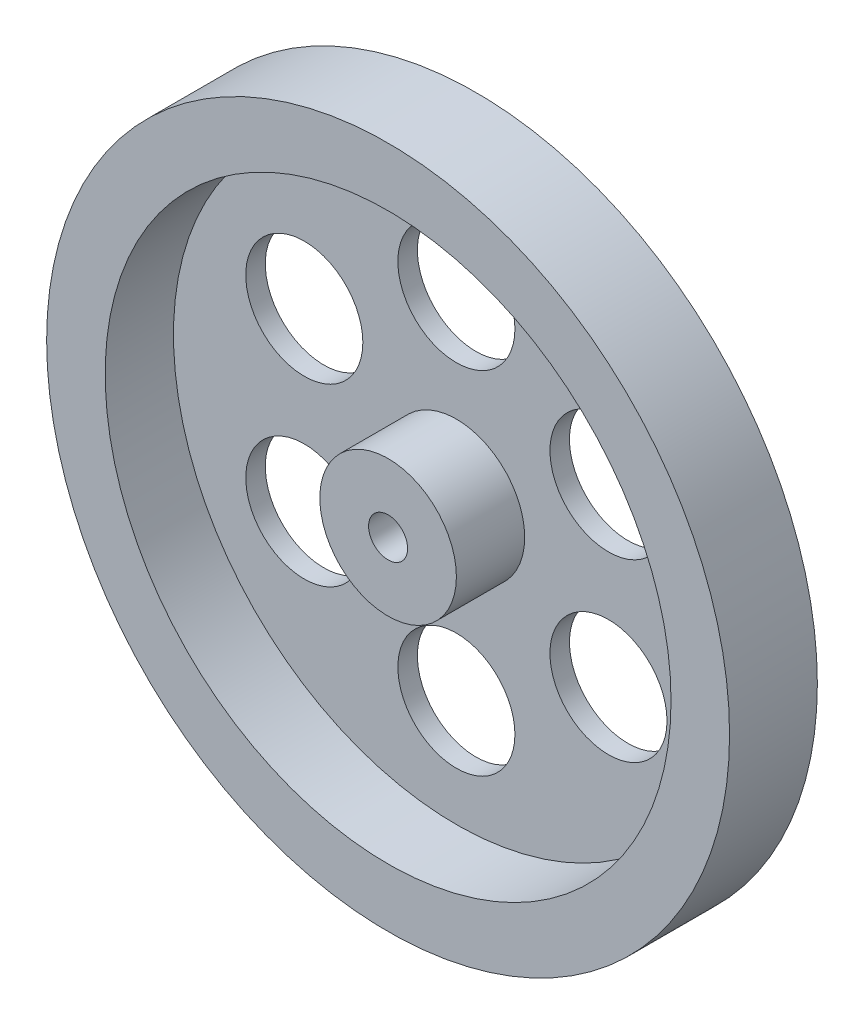
from build123d import *

# Parameters (mm, degrees)
SKETCH1_R               = 35
BOSS_EXTRUDE1_DEPTH     = 9
SKETCH2_R               = 2
CUT_EXTRUDE1_DEPTH      = 1
CUT_EXTRUDE1_DEPTH_BACK = 10
SKETCH3_R               = 29
SKETCH3_R_2             = 7
CUT_EXTRUDE2_DEPTH      = 7
SKETCH4_R               = 6
CUT_EXTRUDE3_DEPTH      = 3


with BuildPart() as part:
    # Sketch1 → Boss-Extrude1 (new body)
    with BuildSketch(Plane.XY):
        Circle(SKETCH1_R)
    extrude(amount=BOSS_EXTRUDE1_DEPTH)

    # Sketch2 → Cut-Extrude1 (cut, two sides)
    with BuildSketch(Plane.XY.offset(9)) as cut_extrude1_sk:
        Circle(SKETCH2_R)
    extrude(amount=CUT_EXTRUDE1_DEPTH, mode=Mode.SUBTRACT)
    extrude(cut_extrude1_sk.sketch, amount=-CUT_EXTRUDE1_DEPTH_BACK, mode=Mode.SUBTRACT)

    # Sketch3 → Cut-Extrude2 (cut)
    with BuildSketch(Plane.XY.offset(9)):
        Circle(SKETCH3_R)
        Circle(SKETCH3_R_2, mode=Mode.SUBTRACT)
    extrude(amount=-CUT_EXTRUDE2_DEPTH, mode=Mode.SUBTRACT)

    # Sketch4 → Cut-Extrude3 (cut, through all)
    with BuildSketch(Plane.XY.offset(2)):
        with Locations((0, 18)):
            Circle(SKETCH4_R)
        with Locations((15.588457268, 9)):
            Circle(SKETCH4_R)
        with Locations((15.588457268, -9)):
            Circle(SKETCH4_R)
        with Locations((0, -18)):
            Circle(SKETCH4_R)
        with Locations((-15.588457268, -9)):
            Circle(SKETCH4_R)
        with Locations((-15.588457268, 9)):
            Circle(SKETCH4_R)
    extrude(amount=-CUT_EXTRUDE3_DEPTH, mode=Mode.SUBTRACT)


solid = part.part
